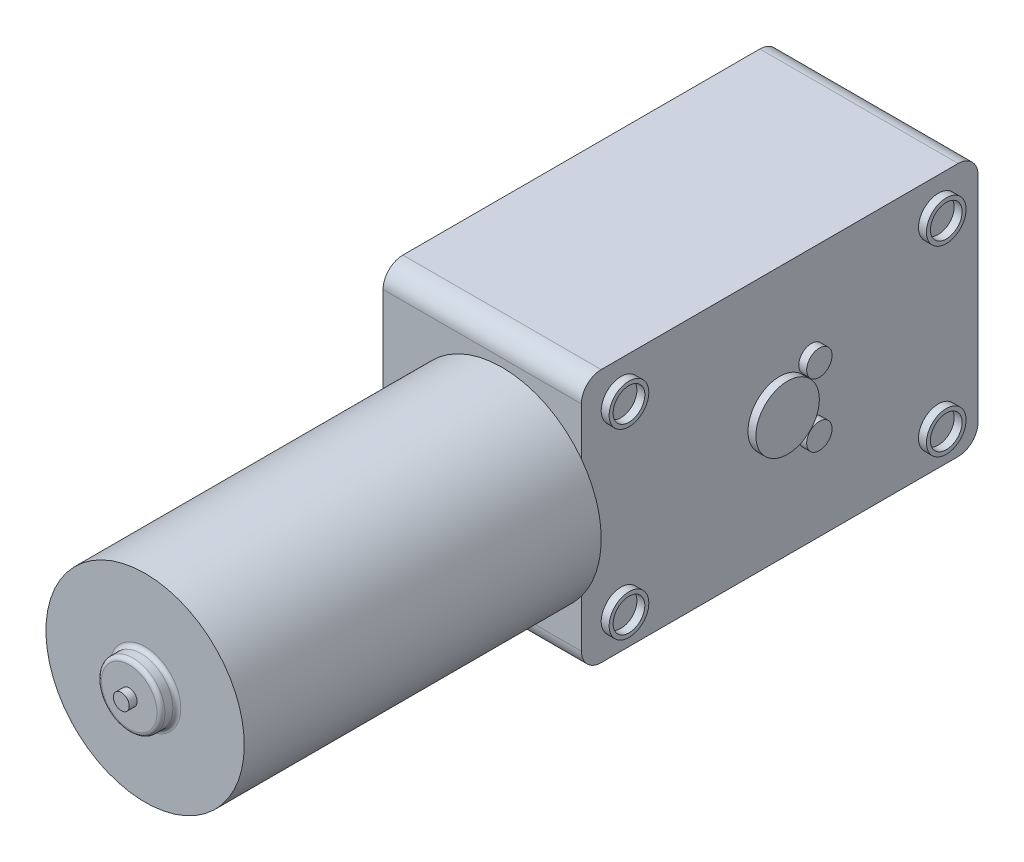
from build123d import *

# Parameters (mm, degrees)
SKETCH4_W           = 50
SKETCH4_H           = 32
BOSS_EXTRUDE1_DEPTH = 25
SKETCH5_R           = 2
CUT_EXTRUDE1_DEPTH  = 5
SKETCH2_R           = 2.5
SKETCH2_R_2         = 2
BOSS_EXTRUDE2_DEPTH = 1
SKETCH7_R           = 4
SKETCH7_R_2         = 1.6
BOSS_EXTRUDE3_DEPTH = 1
FILLET1_R           = 2.5
SKETCH8_R           = 12.5
BOSS_EXTRUDE4_DEPTH = 45
SKETCH10_R          = 4
BOSS_EXTRUDE5_DEPTH = 2
SKETCH11_R          = 1
BOSS_EXTRUDE6_DEPTH = 1
FILLET2_R           = 0.5


with BuildPart() as part:
    # Sketch4 → Boss-Extrude1 (new body)
    with BuildSketch(Plane(origin=(83.969208633, 0, 0), x_dir=(0, 0, -1), z_dir=(1, 0, 0))):
        with Locations((-28, 7.3)):
            Rectangle(SKETCH4_W, SKETCH4_H)
    extrude(amount=BOSS_EXTRUDE1_DEPTH)

    # Sketch5 → Cut-Extrude1 (cut)
    with BuildSketch(Plane.ZY.offset(-83.969208633)):
        with Locations((8, 18.8)):
            Circle(SKETCH5_R)
        with Locations((48, 18.8)):
            Circle(SKETCH5_R)
        with Locations((48, -4.2)):
            Circle(SKETCH5_R)
        with Locations((8, -4.2)):
            Circle(SKETCH5_R)
    extrude(amount=-CUT_EXTRUDE1_DEPTH, mode=Mode.SUBTRACT)

    # Sketch2 → Boss-Extrude2 (add)
    with BuildSketch(Plane(origin=(108.969208633, 0, 0), x_dir=(0, 0, -1), z_dir=(1, 0, 0))):
        with Locations((-48, 18.8)):
            Circle(SKETCH2_R)
        with Locations((-48, 18.8)):
            Circle(SKETCH2_R_2, mode=Mode.SUBTRACT)
        with Locations((-8, 18.8)):
            Circle(SKETCH2_R)
        with Locations((-8, 18.8)):
            Circle(SKETCH2_R_2, mode=Mode.SUBTRACT)
        with Locations((-8, -4.2)):
            Circle(SKETCH2_R)
        with Locations((-8, -4.2)):
            Circle(SKETCH2_R_2, mode=Mode.SUBTRACT)
        with Locations((-48, -4.2)):
            Circle(SKETCH2_R)
        with Locations((-48, -4.2)):
            Circle(SKETCH2_R_2, mode=Mode.SUBTRACT)
    extrude(amount=BOSS_EXTRUDE2_DEPTH)

    # Sketch7 → Boss-Extrude3 (add)
    with BuildSketch(Plane(origin=(108.969208633, 0, 0), x_dir=(0, 0, -1), z_dir=(1, 0, 0))):
        with Locations((-28, 7.3)):
            Circle(SKETCH7_R)
        with Locations((-24, 11.3)):
            Circle(SKETCH7_R_2)
        with Locations((-24, 3.3)):
            Circle(SKETCH7_R_2)
    extrude(amount=BOSS_EXTRUDE3_DEPTH)

    # Fillet1
    fillet1_edges = [part.edges().sort_by_distance(p)[0] for p in [
        (96.469208633, 23.3, 53),
        (96.469208633, 23.3, 3),
        (96.469208633, -8.7, 3),
        (96.469208633, -8.7, 53),
    ]]
    fillet(fillet1_edges, radius=FILLET1_R)

    # Sketch8 → Boss-Extrude4 (add)
    with BuildSketch(Plane.XY.offset(53)):
        with Locations((98.969208633, 7.3)):
            Circle(SKETCH8_R)
    extrude(amount=BOSS_EXTRUDE4_DEPTH)

    # Sketch10 → Boss-Extrude5 (add)
    with BuildSketch(Plane.XY.offset(98)):
        with Locations((98.969208633, 7.3)):
            Circle(SKETCH10_R)
    extrude(amount=BOSS_EXTRUDE5_DEPTH)

    # Sketch11 → Boss-Extrude6 (add)
    with BuildSketch(Plane.XY.offset(100)):
        with Locations((98.969208633, 7.3)):
            Circle(SKETCH11_R)
    extrude(amount=BOSS_EXTRUDE6_DEPTH)

    # Fillet2
    fillet2_edges = [part.edges().sort_by_distance(p)[0] for p in [
        (94.969208633, 7.3, 98),
        (94.969208633, 7.3, 100),
    ]]
    fillet(fillet2_edges, radius=FILLET2_R)


solid = part.part
